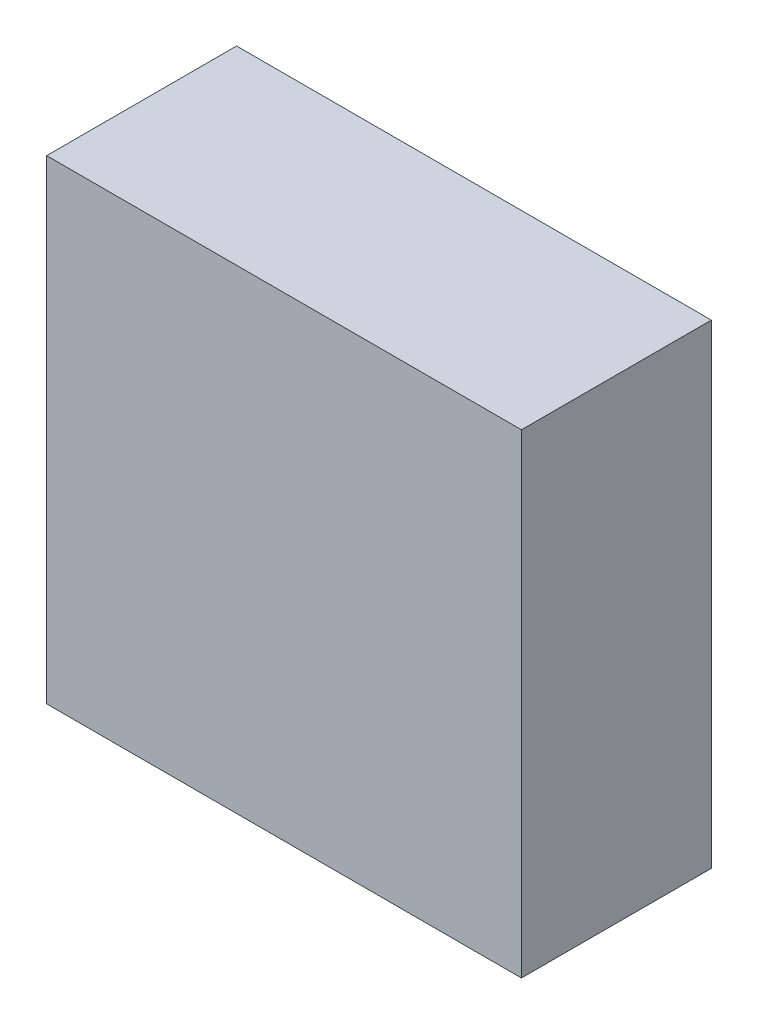
from build123d import *

# Parameters (mm, degrees)
SKETCH1_W           = 15
SKETCH1_H           = 15
BOSS_EXTRUDE1_DEPTH = 5
SKETCH2_W           = 15
SKETCH2_H           = 15
BOSS_EXTRUDE2_DEPTH = 1


with BuildPart() as part:
    # Sketch1 → Boss-Extrude1 (new body)
    with BuildSketch(Plane.XY):
        Rectangle(SKETCH1_W, SKETCH1_H)
        Polygon((-5.55, 5.55), (-1.5, 5.55), (-1.5, 3.55), (1.5, 3.55), (1.5, 5.55), (5.55, 5.55), (5.55, 1.5), (3.55, 1.5), (3.55, -1.5), (5.55, -1.5), (5.55, -5.55), (1.5, -5.55), (1.5, -3.55), (-1.5, -3.55), (-1.5, -5.55), (-5.55, -5.55), (-5.55, -1.5), (-3.55, -1.5), (-3.55, 1.5), (-5.55, 1.5), align=None, mode=Mode.SUBTRACT)
    extrude(amount=BOSS_EXTRUDE1_DEPTH)

    # Sketch2 → Boss-Extrude2 (add)
    with BuildSketch(Plane.XY.offset(5)):
        Rectangle(SKETCH2_W, SKETCH2_H)
    extrude(amount=BOSS_EXTRUDE2_DEPTH)


solid = part.part
